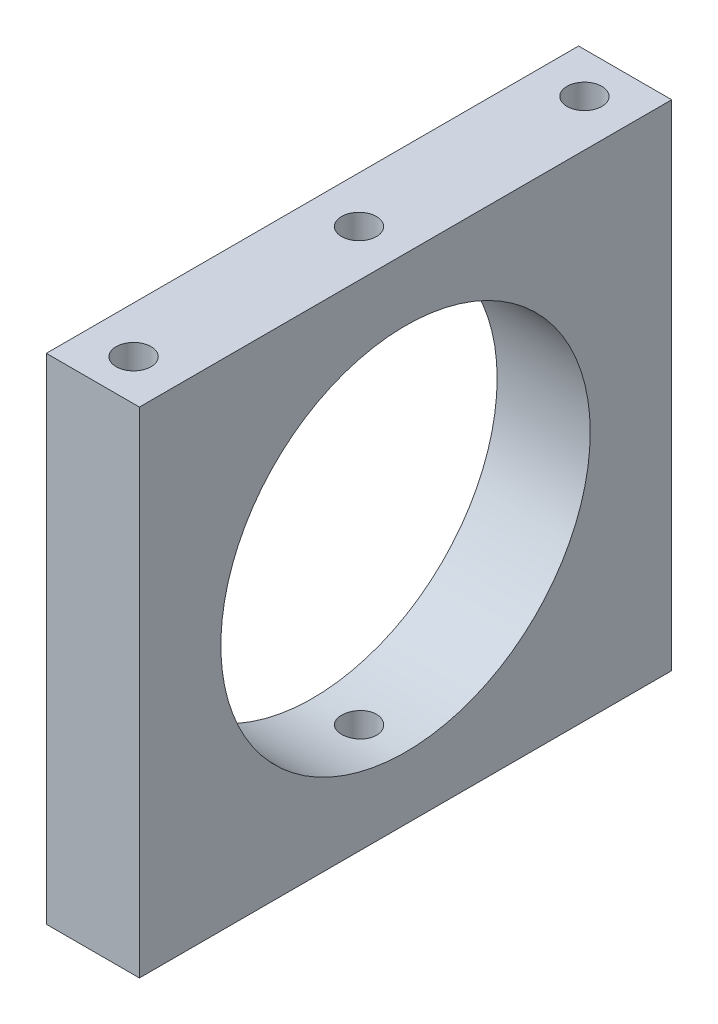
from build123d import *

# Parameters (mm, degrees)
SKETCH2_W           = 8.001
SKETCH2_H           = 45.75
SKETCH2_R           = 1.5
BOSS_EXTRUDE1_DEPTH = 42.5
SKETCH3_R           = 15.875
CUT_EXTRUDE1_DEPTH  = 42.5


with BuildPart() as part:
    # Sketch2 → Boss-Extrude1 (new body)
    with BuildSketch(Plane(origin=(0, 0, 0), x_dir=(1, 0, 0), z_dir=(0, 1, 0))):
        Rectangle(SKETCH2_W, SKETCH2_H)
        Circle(SKETCH2_R, mode=Mode.SUBTRACT)
        with Locations((0, 19.375)):
            Circle(SKETCH2_R, mode=Mode.SUBTRACT)
        with Locations((0, -19.375)):
            Circle(SKETCH2_R, mode=Mode.SUBTRACT)
    extrude(amount=BOSS_EXTRUDE1_DEPTH)

    # Sketch3 → Cut-Extrude1 (cut)
    with BuildSketch(Plane(origin=(4.0005, 0, 0), x_dir=(0, 0, -1), z_dir=(1, 0, 0))):
        with Locations((0, 21.25)):
            Circle(SKETCH3_R)
    extrude(amount=-CUT_EXTRUDE1_DEPTH, mode=Mode.SUBTRACT)


solid = part.part
